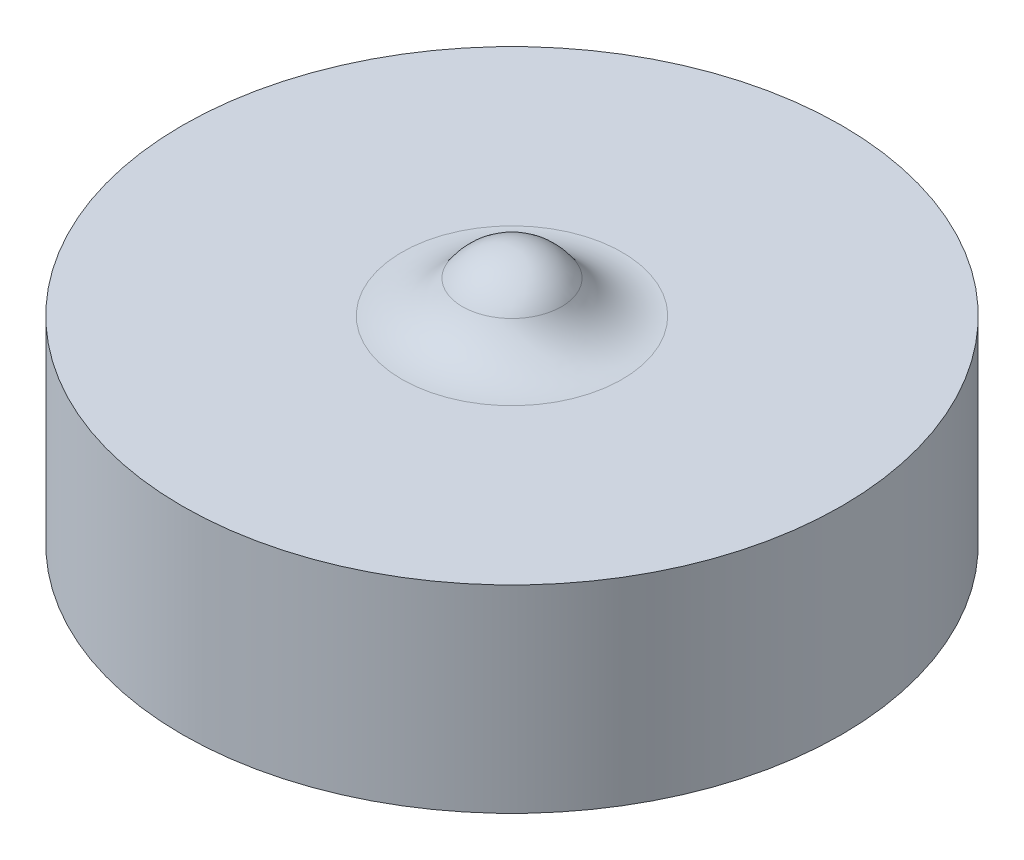
from build123d import *

# Parameters (mm, degrees)
SKETCH_1_R      = 5
EXTRUDE_1_DEPTH = 3
FILLET_1_R      = 1.1


with BuildPart() as part:
    # 草图1 → 凸台-拉伸1 (new body)
    with BuildSketch(Plane(origin=(0, 0, 0), x_dir=(1, 0, 0), z_dir=(0, 1, 0))):
        Circle(SKETCH_1_R)
    extrude(amount=EXTRUDE_1_DEPTH)

    # 草图2 → 旋转1 (revolve)
    with BuildSketch(Plane.XY):
        with BuildLine():
            Line((0, 3.9), (0, 3))
            Line((0, 3), (0.9, 3))
            ThreePointArc((0.9, 3), (0.636396103, 3.636396103), (0, 3.9))
        make_face()
    revolve(axis=Axis((0, 0, 0), (0, 1, 0)))

    # 圆角1
    fillet_1_edges = [part.edges().sort_by_distance(p)[0] for p in [
        (-0.9, 3, 0),
    ]]
    fillet(fillet_1_edges, radius=FILLET_1_R)


solid = part.part
